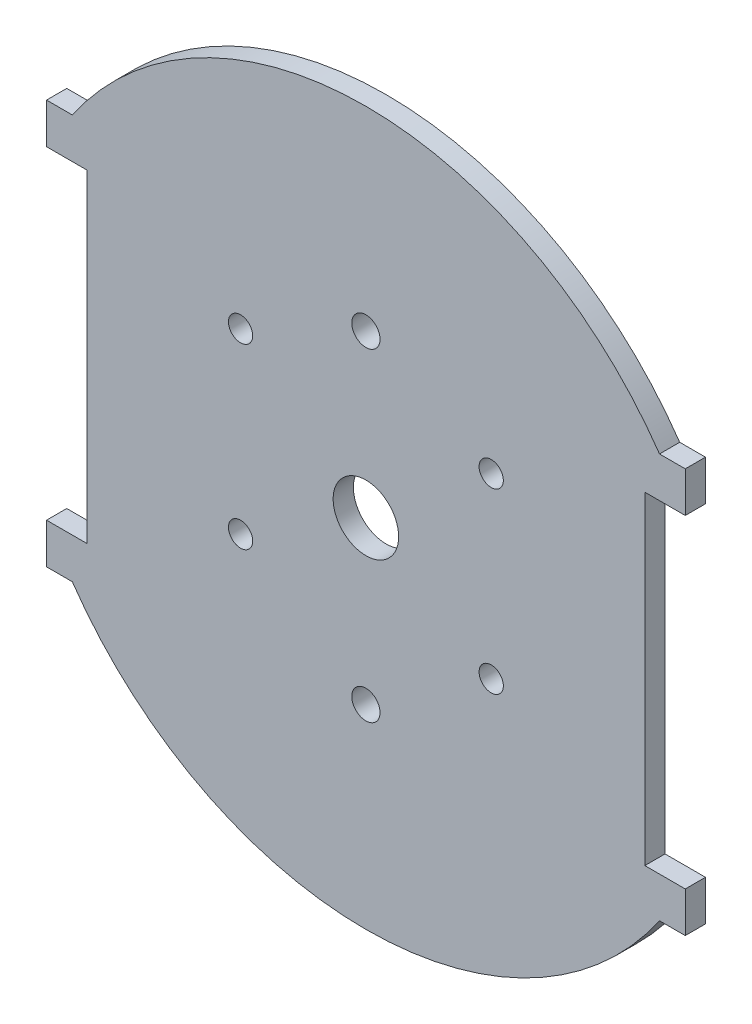
from build123d import *

# Parameters (mm, degrees)
CROQUIS1_R              = 4.05
CROQUIS1_R_2            = 1.75
SALIENTE_EXTRUIR1_DEPTH = 2.5
CROQUIS2_R              = 1.5
CORTAR_EXTRUIR1_DEPTH   = 4


with BuildPart() as part:
    # Croquis1 → Saliente-Extruir1 (new body)
    with BuildSketch(Plane.XY):
        with BuildLine():
            Line((-39.500346279, 20), (-34.500346279, 20))
            Line((-34.500346279, 20), (-34.500346279, -20))
            Line((-34.500346279, -20), (-39.500346279, -20))
            Line((-39.500346279, -20), (-39.500346279, -25))
            Line((-39.500346279, -25), (-36.317049715, -25))
            ThreePointArc((-36.317049715, -25), (0, -44.09), (36.317049715, -25))
            Line((36.317049715, -25), (39.500346279, -25))
            Line((39.500346279, -25), (39.500346279, -20))
            Line((39.500346279, -20), (34.500346279, -20))
            Line((34.500346279, -20), (34.500346279, 20))
            Line((34.500346279, 20), (39.500346279, 20))
            Line((39.500346279, 20), (39.500346279, 25))
            Line((39.500346279, 25), (36.317049715, 25))
            ThreePointArc((36.317049715, 25), (0, 44.09), (-36.317049715, 25))
            Line((-36.317049715, 25), (-39.500346279, 25))
            Line((-39.500346279, 25), (-39.500346279, 20))
        make_face()
        Circle(CROQUIS1_R, mode=Mode.SUBTRACT)
        with Locations((0, 20)):
            Circle(CROQUIS1_R_2, mode=Mode.SUBTRACT)
        with Locations((0, -20)):
            Circle(CROQUIS1_R_2, mode=Mode.SUBTRACT)
    extrude(amount=SALIENTE_EXTRUIR1_DEPTH)

    # Croquis2 → Cortar-Extruir1 (cut)
    with BuildSketch(Plane(origin=(0, 0, 0), x_dir=(-1, 0, 0), z_dir=(0, 0, -1))):
        with Locations((15.5, -9.5)):
            Circle(CROQUIS2_R)
        with Locations((15.5, 12.5)):
            Circle(CROQUIS2_R)
        with Locations((-15.5, 12.5)):
            Circle(CROQUIS2_R)
        with Locations((-15.5, -9.5)):
            Circle(CROQUIS2_R)
    extrude(amount=-CORTAR_EXTRUIR1_DEPTH, mode=Mode.SUBTRACT)


solid = part.part
